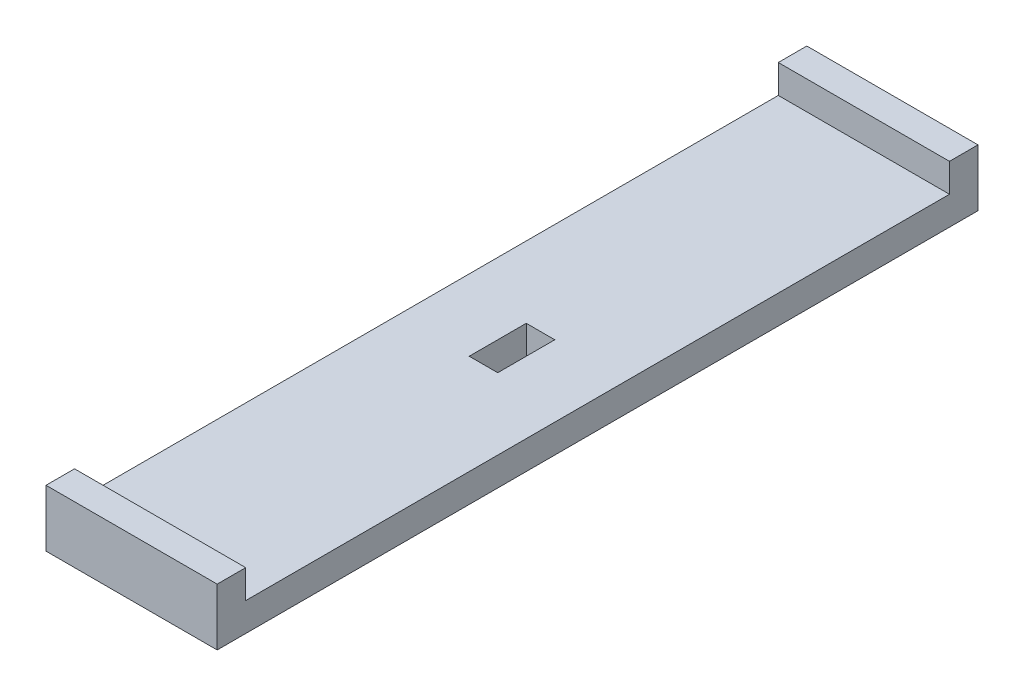
from build123d import *

# Parameters (mm, degrees)
SKETCH1_W           = 18
SKETCH1_H           = 80
SKETCH1_W_2         = 3
SKETCH1_H_2         = 6
BOSS_EXTRUDE1_DEPTH = 3
SKETCH2_W           = 18
SKETCH2_H           = 3
BOSS_EXTRUDE2_DEPTH = 3


with BuildPart() as part:
    # Sketch1 → Boss-Extrude1 (new body)
    with BuildSketch(Plane(origin=(0, 0, 0), x_dir=(1, 0, 0), z_dir=(0, 1, 0))):
        Rectangle(SKETCH1_W, SKETCH1_H)
        Rectangle(SKETCH1_W_2, SKETCH1_H_2, mode=Mode.SUBTRACT)
    extrude(amount=BOSS_EXTRUDE1_DEPTH)

    # Sketch2 → Boss-Extrude2 (add)
    with BuildSketch(Plane(origin=(0, 3, 0), x_dir=(1, 0, 0), z_dir=(0, 1, 0))):
        with Locations((0, -38.5)):
            Rectangle(SKETCH2_W, SKETCH2_H)
        with Locations((0, 38.5)):
            Rectangle(SKETCH2_W, SKETCH2_H)
    extrude(amount=BOSS_EXTRUDE2_DEPTH)


solid = part.part
